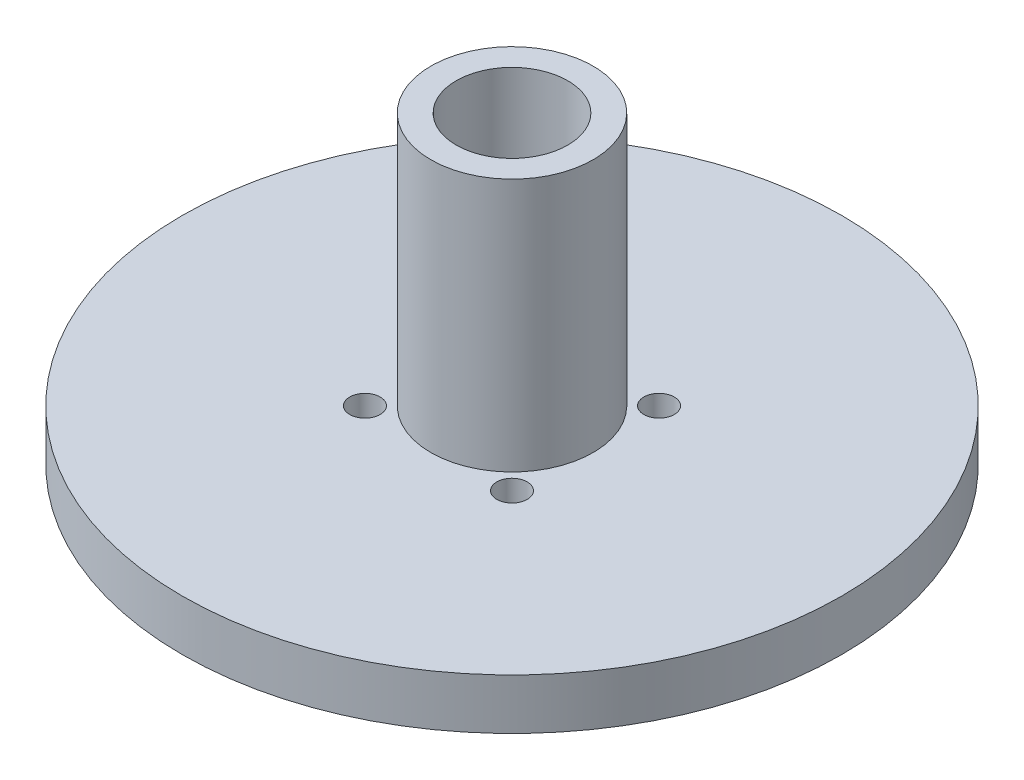
from build123d import *

# Parameters (mm, degrees)
SKETCH1_R           = 32.5
SKETCH1_R_2         = 17.5
SKETCH1_R_3         = 12.5
SKETCH1_R_4         = 8
BOSS_EXTRUDE1_DEPTH = 5
SKETCH2_R           = 1.5
CUT_EXTRUDE1_DEPTH  = 10
SKETCH3_R           = 8
SKETCH3_R_2         = 5.5
BOSS_EXTRUDE3_DEPTH = 30


with BuildPart() as part:
    # Sketch1 → Boss-Extrude1 (new body)
    with BuildSketch(Plane(origin=(0, 0, 0), x_dir=(1, 0, 0), z_dir=(0, 1, 0))):
        Circle(SKETCH1_R)
        Circle(SKETCH1_R_2, mode=Mode.SUBTRACT)
        Circle(SKETCH1_R_2)
        Circle(SKETCH1_R_3, mode=Mode.SUBTRACT)
        Circle(SKETCH1_R_3)
        Circle(SKETCH1_R_4, mode=Mode.SUBTRACT)
    extrude(amount=BOSS_EXTRUDE1_DEPTH)

    # Sketch2 → Cut-Extrude1 (cut)
    with BuildSketch(Plane(origin=(0, 0, 0), x_dir=(1, 0, 0), z_dir=(0, 1, 0))):
        with Locations((-7.247844507, 7.247844507)):
            Circle(SKETCH2_R)
        with Locations((7.247844507, 7.247844507)):
            Circle(SKETCH2_R)
        with Locations((7.247844507, -7.247844507)):
            Circle(SKETCH2_R)
        with Locations((-7.247844507, -7.247844507)):
            Circle(SKETCH2_R)
    extrude(amount=CUT_EXTRUDE1_DEPTH, mode=Mode.SUBTRACT)

    # Sketch3 → Boss-Extrude3 (add)
    with BuildSketch(Plane(origin=(0, 0, 0), x_dir=(1, 0, 0), z_dir=(0, 1, 0))):
        Circle(SKETCH3_R)
        Circle(SKETCH3_R_2, mode=Mode.SUBTRACT)
    extrude(amount=BOSS_EXTRUDE3_DEPTH)


solid = part.part
